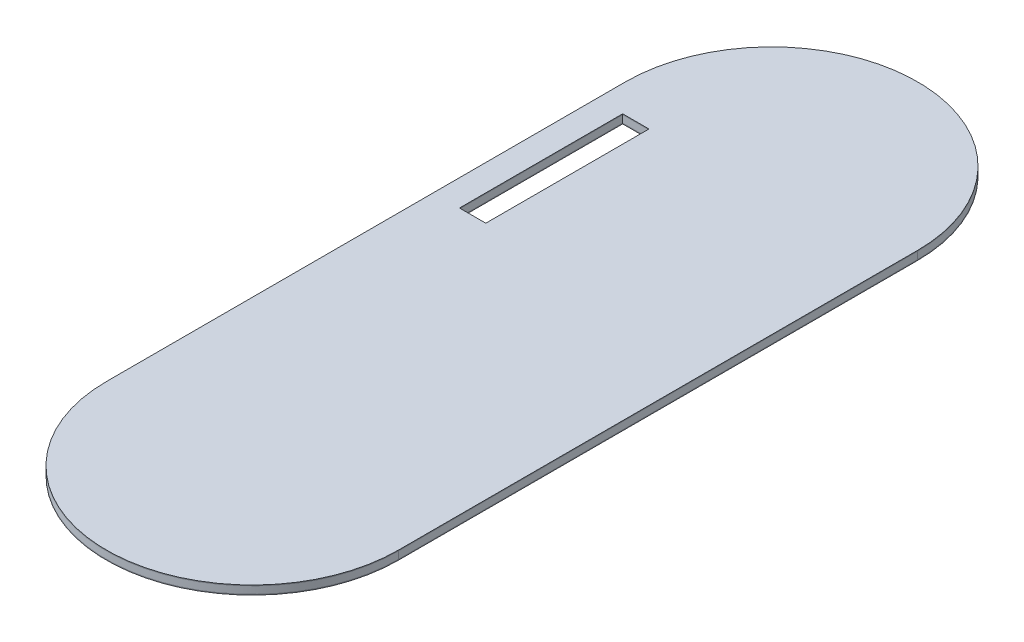
from build123d import *

# Parameters (mm, degrees)
SKETCH1_W           = 9
SKETCH1_H           = 55.88
BOSS_EXTRUDE1_DEPTH = 0.25
SKETCH2_W           = 9
SKETCH2_H           = 55.88
BOSS_EXTRUDE3_DEPTH = 2.5
SKETCH3_W           = 9
SKETCH3_H           = 55.88
BOSS_EXTRUDE4_DEPTH = 0.25


with BuildPart() as part:
    # Sketch1 → Boss-Extrude1 (new body)
    with BuildSketch(Plane(origin=(0, 0, 0), x_dir=(1, 0, 0), z_dir=(0, 1, 0))):
        with BuildLine():
            Line((50, 88.9), (50, -88.9))
            ThreePointArc((50, -88.9), (0, -138.9), (-50, -88.9))
            Line((-50, -88.9), (-50, 88.9))
            ThreePointArc((-50, 88.9), (0, 138.9), (50, 88.9))
        make_face()
        with Locations((-36.5, 50.96)):
            Rectangle(SKETCH1_W, SKETCH1_H, mode=Mode.SUBTRACT)
    extrude(amount=BOSS_EXTRUDE1_DEPTH)


with BuildPart() as body_2:
    # Sketch2 → Boss-Extrude3 (new body)
    with BuildSketch(Plane(origin=(0, 0.25, 0), x_dir=(1, 0, 0), z_dir=(0, 1, 0))):
        with BuildLine():
            ThreePointArc((50, 88.9), (0, 138.9), (-50, 88.9))
            Line((-50, 88.9), (-50, -88.9))
            ThreePointArc((-50, -88.9), (0, -138.9), (50, -88.9))
            Line((50, -88.9), (50, 88.9))
        make_face()
        with Locations((-36.5, 50.96)):
            Rectangle(SKETCH2_W, SKETCH2_H, mode=Mode.SUBTRACT)
    extrude(amount=BOSS_EXTRUDE3_DEPTH)


with BuildPart() as body_3:
    # Sketch3 → Boss-Extrude4 (new body)
    with BuildSketch(Plane(origin=(0, 2.75, 0), x_dir=(1, 0, 0), z_dir=(0, 1, 0))):
        with BuildLine():
            ThreePointArc((-50, -88.9), (0, -138.9), (50, -88.9))
            Line((50, -88.9), (50, 88.9))
            ThreePointArc((50, 88.9), (0, 138.9), (-50, 88.9))
            Line((-50, 88.9), (-50, -88.9))
        make_face()
        with Locations((-36.5, 50.96)):
            Rectangle(SKETCH3_W, SKETCH3_H, mode=Mode.SUBTRACT)
    extrude(amount=BOSS_EXTRUDE4_DEPTH)


solid = Compound([part.part, body_2.part, body_3.part])
